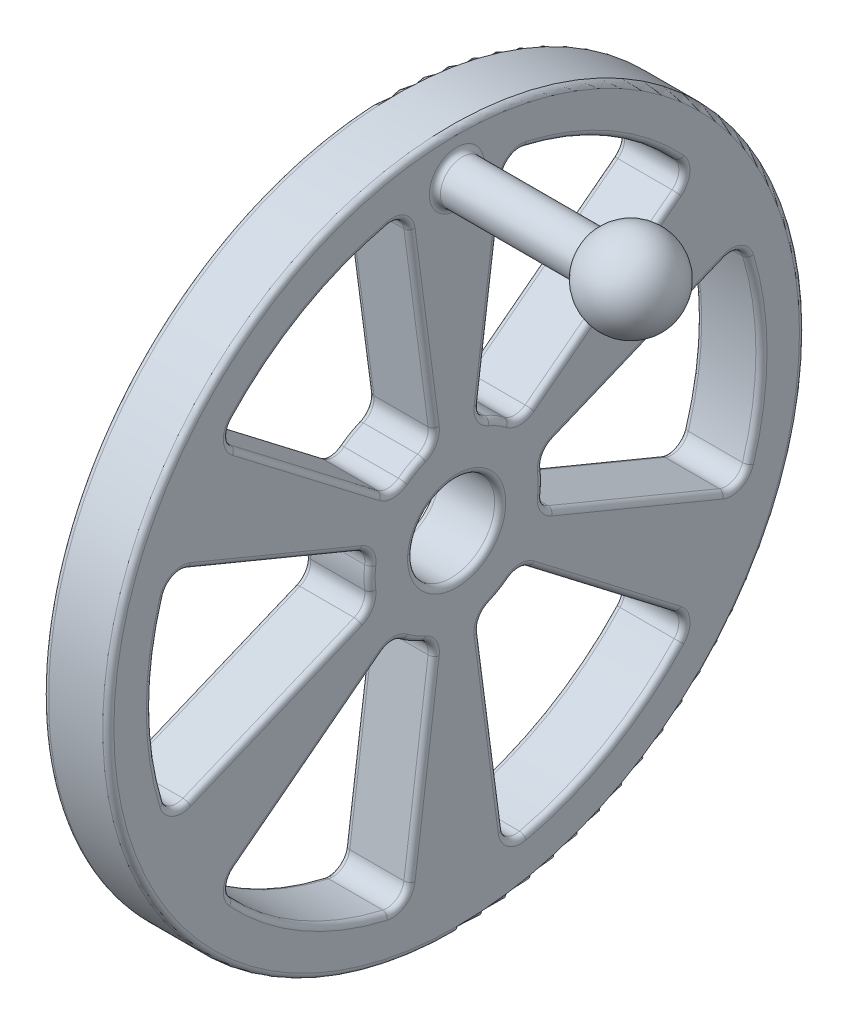
from build123d import *

# Parameters (mm, degrees)
SKETCH1_R           = 50.8
SKETCH1_R_2         = 6.35
BOSS_EXTRUDE2_DEPTH = 4.7625
FILLET1_R           = 0.8128


with BuildPart() as part:
    # Sketch1 → Boss-Extrude2 (new body, symmetric)
    with BuildSketch(Plane(origin=(0, 0, 0), x_dir=(0, 0, -1), z_dir=(1, 0, 0))):
        Circle(SKETCH1_R)
        Circle(SKETCH1_R_2, mode=Mode.SUBTRACT)
        with BuildLine():
            Line((14.143172771, 4.293104855), (39.097644593, 14.629585525))
            ThreePointArc((39.097644593, 14.629585525), (41.152295647, 14.580648023), (42.498124784, 13.027351604))
            ThreePointArc((42.498124784, 13.027351604), (44.45, 0), (42.498124784, -13.027351604))
            ThreePointArc((42.498124784, -13.027351604), (41.152295647, -14.580648023), (39.097644593, -14.629585525))
            Line((39.097644593, -14.629585525), (14.143172771, -4.293104855))
            ThreePointArc((14.143172771, -4.293104855), (12.917283424, -3.219562166), (12.595990575, -1.622042369))
            ThreePointArc((12.595990575, -1.622042369), (12.7, 0), (12.595990575, 1.622042369))
            ThreePointArc((12.595990575, 1.622042369), (12.917283424, 3.219562166), (14.143172771, 4.293104855))
        make_face(mode=Mode.SUBTRACT)
        with BuildLine():
            Line((10.789524251, -10.101794482), (32.218415008, -26.544760683))
            ThreePointArc((32.218415008, -26.544760683), (33.203359415, -28.348609442), (32.531079826, -30.290779874))
            ThreePointArc((32.531079826, -30.290779874), (22.225, -38.494829198), (9.967044959, -43.318131479))
            ThreePointArc((9.967044959, -43.318131479), (7.948936231, -42.929257466), (6.879229585, -41.174346208))
            Line((6.879229585, -41.174346208), (3.35364852, -14.394899338))
            ThreePointArc((3.35364852, -14.394899338), (3.670419087, -12.796476676), (4.89326539, -11.719469008))
            ThreePointArc((4.89326539, -11.719469008), (6.35, -10.998522628), (7.702725185, -10.097426639))
            ThreePointArc((7.702725185, -10.097426639), (9.246864337, -9.57691451), (10.789524251, -10.101794482))
        make_face(mode=Mode.SUBTRACT)
        with BuildLine():
            Line((-3.35364852, -14.394899338), (-6.879229585, -41.174346208))
            ThreePointArc((-6.879229585, -41.174346208), (-7.948936231, -42.929257466), (-9.967044959, -43.318131479))
            ThreePointArc((-9.967044959, -43.318131479), (-22.225, -38.494829198), (-32.531079826, -30.290779874))
            ThreePointArc((-32.531079826, -30.290779874), (-33.203359415, -28.348609442), (-32.218415008, -26.544760683))
            Line((-32.218415008, -26.544760683), (-10.789524251, -10.101794482))
            ThreePointArc((-10.789524251, -10.101794482), (-9.246864337, -9.57691451), (-7.702725185, -10.097426639))
            ThreePointArc((-7.702725185, -10.097426639), (-6.35, -10.998522628), (-4.89326539, -11.719469008))
            ThreePointArc((-4.89326539, -11.719469008), (-3.670419087, -12.796476676), (-3.35364852, -14.394899338))
        make_face(mode=Mode.SUBTRACT)
        with BuildLine():
            Line((-14.143172771, -4.293104855), (-39.097644593, -14.629585525))
            ThreePointArc((-39.097644593, -14.629585525), (-41.152295647, -14.580648023), (-42.498124784, -13.027351604))
            ThreePointArc((-42.498124784, -13.027351604), (-44.45, 0), (-42.498124784, 13.027351604))
            ThreePointArc((-42.498124784, 13.027351604), (-41.152295647, 14.580648023), (-39.097644593, 14.629585525))
            Line((-39.097644593, 14.629585525), (-14.143172771, 4.293104855))
            ThreePointArc((-14.143172771, 4.293104855), (-12.917283424, 3.219562166), (-12.595990575, 1.622042369))
            ThreePointArc((-12.595990575, 1.622042369), (-12.7, 0), (-12.595990575, -1.622042369))
            ThreePointArc((-12.595990575, -1.622042369), (-12.917283424, -3.219562166), (-14.143172771, -4.293104855))
        make_face(mode=Mode.SUBTRACT)
        with BuildLine():
            Line((-10.789524251, 10.101794482), (-32.218415008, 26.544760683))
            ThreePointArc((-32.218415008, 26.544760683), (-33.203359415, 28.348609442), (-32.531079826, 30.290779874))
            ThreePointArc((-32.531079826, 30.290779874), (-22.225, 38.494829198), (-9.967044959, 43.318131479))
            ThreePointArc((-9.967044959, 43.318131479), (-7.948936231, 42.929257466), (-6.879229585, 41.174346208))
            Line((-6.879229585, 41.174346208), (-3.35364852, 14.394899338))
            ThreePointArc((-3.35364852, 14.394899338), (-3.670419087, 12.796476676), (-4.89326539, 11.719469008))
            ThreePointArc((-4.89326539, 11.719469008), (-6.35, 10.998522628), (-7.702725185, 10.097426639))
            ThreePointArc((-7.702725185, 10.097426639), (-9.246864337, 9.57691451), (-10.789524251, 10.101794482))
        make_face(mode=Mode.SUBTRACT)
        with BuildLine():
            Line((3.35364852, 14.394899338), (6.879229585, 41.174346208))
            ThreePointArc((6.879229585, 41.174346208), (7.948936231, 42.929257466), (9.967044959, 43.318131479))
            ThreePointArc((9.967044959, 43.318131479), (22.225, 38.494829198), (32.531079826, 30.290779874))
            ThreePointArc((32.531079826, 30.290779874), (33.203359415, 28.348609442), (32.218415008, 26.544760683))
            Line((32.218415008, 26.544760683), (10.789524251, 10.101794482))
            ThreePointArc((10.789524251, 10.101794482), (9.246864337, 9.57691451), (7.702725185, 10.097426639))
            ThreePointArc((7.702725185, 10.097426639), (6.35, 10.998522628), (4.89326539, 11.719469008))
            ThreePointArc((4.89326539, 11.719469008), (3.670419087, 12.796476676), (3.35364852, 14.394899338))
        make_face(mode=Mode.SUBTRACT)
    extrude(amount=BOSS_EXTRUDE2_DEPTH, both=True)

    # Sketch2 → Revolve1 (revolve)
    with BuildSketch(Plane.XY):
        with BuildLine():
            Line((4.7625, 47.625), (24.663238686, 47.625))
            ThreePointArc((24.663238686, 47.625), (31.806000936, 50.583628997), (36.5125, 44.45))
            Line((36.5125, 44.45), (4.7625, 44.45))
            Line((4.7625, 44.45), (4.7625, 47.625))
        make_face()
    revolve(axis=Axis((36.5125, 44.45, 0), (-1, 0, 0)))

    # Fillet1
    fillet1_edges = [part.edges().sort_by_distance(p)[0] for p in [
        (-4.7625, -14.580648023, -41.152295647),
        (-4.7625, 42.929257466, 7.948936231),
        (-4.7625, 38.494829198, 22.225),
        (-4.7625, 28.348609442, 33.203359415),
        (-4.7625, 18.323277583, 21.50396963),
        (-4.7625, 9.57691451, 9.246864337),
        (-4.7625, 10.998522628, 6.35),
        (-4.7625, 12.796476676, 3.670419087),
        (-4.7625, 27.784622773, 5.116439052),
        (-4.7625, 0, -44.45),
        (4.7625, 42.929257466, 7.948936231),
        (4.7625, 38.494829198, 22.225),
        (4.7625, 28.348609442, 33.203359415),
        (4.7625, 18.323277583, 21.50396963),
        (4.7625, 9.57691451, 9.246864337),
        (4.7625, 10.998522628, 6.35),
        (4.7625, 12.796476676, 3.670419087),
        (4.7625, 27.784622773, 5.116439052),
        (-4.7625, 14.580648023, -41.152295647),
        (-4.7625, 9.46134519, -26.620408682),
        (-4.7625, 3.219562166, -12.917283424),
        (-4.7625, 0, -12.7),
        (-4.7625, -3.219562166, -12.917283424),
        (-4.7625, 28.348609442, -33.203359415),
        (-4.7625, 38.494829198, -22.225),
        (-4.7625, 42.929257466, -7.948936231),
        (-4.7625, 27.784622773, -5.116439052),
        (-4.7625, 12.796476676, -3.670419087),
        (-4.7625, 10.998522628, -6.35),
        (-4.7625, 9.57691451, -9.246864337),
        (-4.7625, 18.323277583, -21.50396963),
        (4.7625, 28.348609442, -33.203359415),
        (-4.7625, -9.46134519, -26.620408682),
        (4.7625, 38.494829198, -22.225),
        (4.7625, 42.929257466, -7.948936231),
        (4.7625, 27.784622773, -5.116439052),
        (4.7625, 12.796476676, -3.670419087),
        (4.7625, 10.998522628, -6.35),
        (4.7625, 9.57691451, -9.246864337),
        (4.7625, 18.323277583, -21.50396963),
        (4.7625, -14.580648023, -41.152295647),
        (4.7625, 0, -44.45),
        (4.7625, 14.580648023, -41.152295647),
        (4.7625, 9.46134519, -26.620408682),
        (4.7625, 3.219562166, -12.917283424),
        (4.7625, 0, -12.7),
        (4.7625, -3.219562166, -12.917283424),
        (4.7625, -9.46134519, -26.620408682),
        (4.7625, 41.275, 0),
        (-4.7625, 0, 50.8),
        (-4.7625, 0, 6.35),
        (4.7625, 0, 6.35),
        (-4.7625, -42.929257466, -7.948936231),
        (-4.7625, -38.494829198, -22.225),
        (-4.7625, -28.348609442, -33.203359415),
        (-4.7625, -18.323277583, -21.50396963),
        (4.7625, 0, 50.8),
        (-4.7625, -9.57691451, -9.246864337),
        (-4.7625, -10.998522628, -6.35),
        (-4.7625, -12.796476676, -3.670419087),
        (-4.7625, -27.784622773, -5.116439052),
        (4.7625, -42.929257466, -7.948936231),
        (4.7625, -38.494829198, -22.225),
        (4.7625, -28.348609442, -33.203359415),
        (4.7625, -18.323277583, -21.50396963),
        (4.7625, -9.57691451, -9.246864337),
        (4.7625, -10.998522628, -6.35),
        (4.7625, -12.796476676, -3.670419087),
        (4.7625, -27.784622773, -5.116439052),
        (-4.7625, -28.348609442, 33.203359415),
        (-4.7625, -38.494829198, 22.225),
        (-4.7625, -42.929257466, 7.948936231),
        (-4.7625, -27.784622773, 5.116439052),
        (-4.7625, -12.796476676, 3.670419087),
        (-4.7625, -10.998522628, 6.35),
        (-4.7625, -9.57691451, 9.246864337),
        (-4.7625, -18.323277583, 21.50396963),
        (4.7625, -28.348609442, 33.203359415),
        (4.7625, -38.494829198, 22.225),
        (4.7625, -42.929257466, 7.948936231),
        (4.7625, -27.784622773, 5.116439052),
        (4.7625, -12.796476676, 3.670419087),
        (4.7625, -10.998522628, 6.35),
        (4.7625, -9.57691451, 9.246864337),
        (4.7625, -18.323277583, 21.50396963),
        (-4.7625, 14.580648023, 41.152295647),
        (-4.7625, 0, 44.45),
        (-4.7625, -14.580648023, 41.152295647),
        (-4.7625, -9.46134519, 26.620408682),
        (-4.7625, -3.219562166, 12.917283424),
        (-4.7625, 0, 12.7),
        (-4.7625, 3.219562166, 12.917283424),
        (-4.7625, 9.46134519, 26.620408682),
        (4.7625, 14.580648023, 41.152295647),
        (4.7625, 0, 44.45),
        (4.7625, -14.580648023, 41.152295647),
        (4.7625, -9.46134519, 26.620408682),
        (4.7625, -3.219562166, 12.917283424),
        (4.7625, 0, 12.7),
        (4.7625, 3.219562166, 12.917283424),
        (4.7625, 9.46134519, 26.620408682),
    ]]
    fillet(fillet1_edges, radius=FILLET1_R)


solid = part.part
